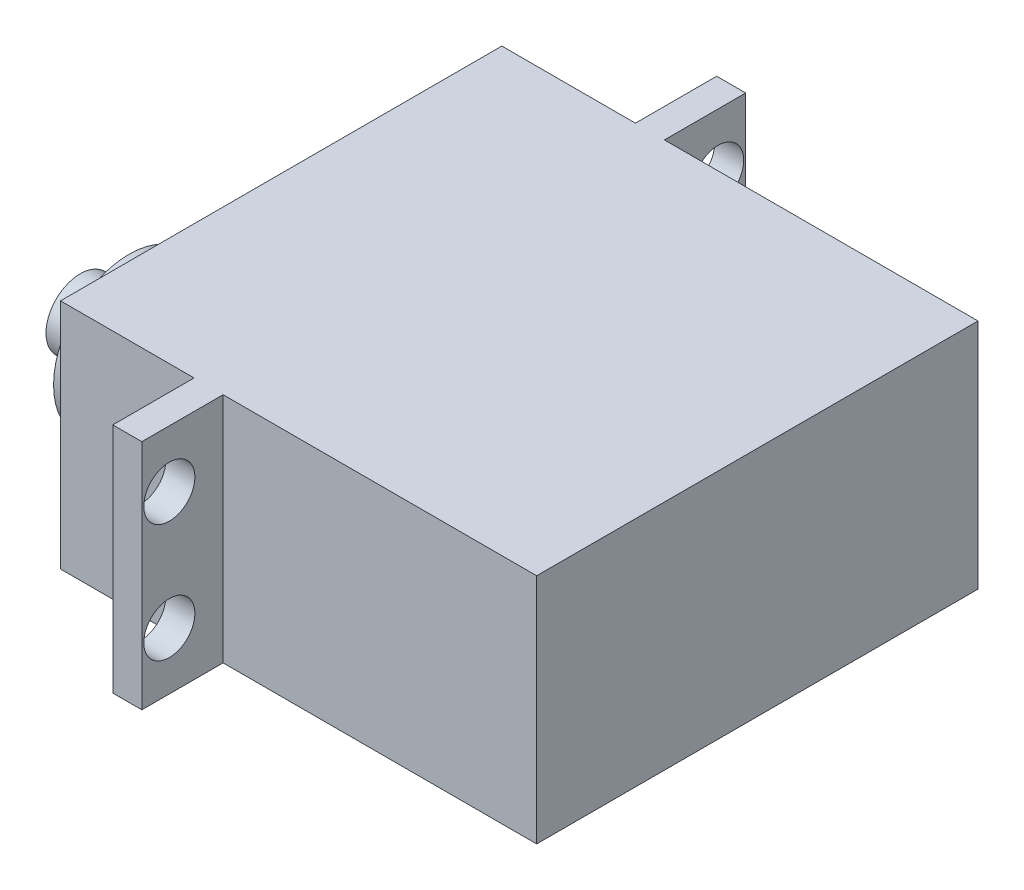
from build123d import *

# Parameters (mm, degrees)
SKETCH1_W                      = 41
SKETCH1_H                      = 20
EXTRUDE1_DEPTH                 = 38
SKETCH2_W                      = 2.5
SKETCH2_H                      = 52
EXTRUDE2_DEPTH                 = 20
SKETCH3_R                      = 6.5
EXTRUDE3_DEPTH                 = 3.8
SKETCH4_R                      = 2.95
EXTRUDE4_DEPTH                 = 4.2
F_4_4_4_4_DIAMETER_HOLE1_D     = 4.4
F_4_4_4_4_DIAMETER_HOLE1_DEPTH = 150
F_4_4_4_4_DIAMETER_HOLE1_TIP   = 1.321893362


with BuildPart() as part:
    # Sketch1 → Extrude1 (new body)
    with BuildSketch(Plane.XY):
        with Locations((0.479801018, -0.224419429)):
            Rectangle(SKETCH1_W, SKETCH1_H)
    extrude(amount=EXTRUDE1_DEPTH)

    # Sketch2 → Extrude2 (add)
    with BuildSketch(Plane(origin=(0, 9.775580571, 0), x_dir=(1, 0, 0), z_dir=(0, 1, 0))):
        with Locations((-7.270198982, -19)):
            Rectangle(SKETCH2_W, SKETCH2_H)
    extrude(amount=-EXTRUDE2_DEPTH)

    # Sketch3 → Extrude3 (add)
    with BuildSketch(Plane.ZY.offset(20.020198982)):
        with Locations((28.3, 0)):
            Circle(SKETCH3_R)
    extrude(amount=EXTRUDE3_DEPTH)

    # Sketch4 → Extrude4 (add)
    with BuildSketch(Plane.ZY.offset(23.820198982)):
        with Locations((28.3, 0)):
            Circle(SKETCH4_R)
    extrude(amount=EXTRUDE4_DEPTH)

    # Ø4.4 (4.4) Diameter Hole1
    with Locations(Plane(origin=(-8.520198982, 4.860580571, -4.63), x_dir=(0, 0, -1), z_dir=(-1, 0, 0))):
        with Locations((0, 0), (0, 10.17), (-47.26, 0), (-47.26, 10.17)):
            Hole(F_4_4_4_4_DIAMETER_HOLE1_D / 2, depth=F_4_4_4_4_DIAMETER_HOLE1_DEPTH)
            with Locations((0, 0, -(F_4_4_4_4_DIAMETER_HOLE1_DEPTH + F_4_4_4_4_DIAMETER_HOLE1_TIP / 2))):  # 118° drill point
                Cone(0, F_4_4_4_4_DIAMETER_HOLE1_D / 2, F_4_4_4_4_DIAMETER_HOLE1_TIP, mode=Mode.SUBTRACT)


solid = part.part
